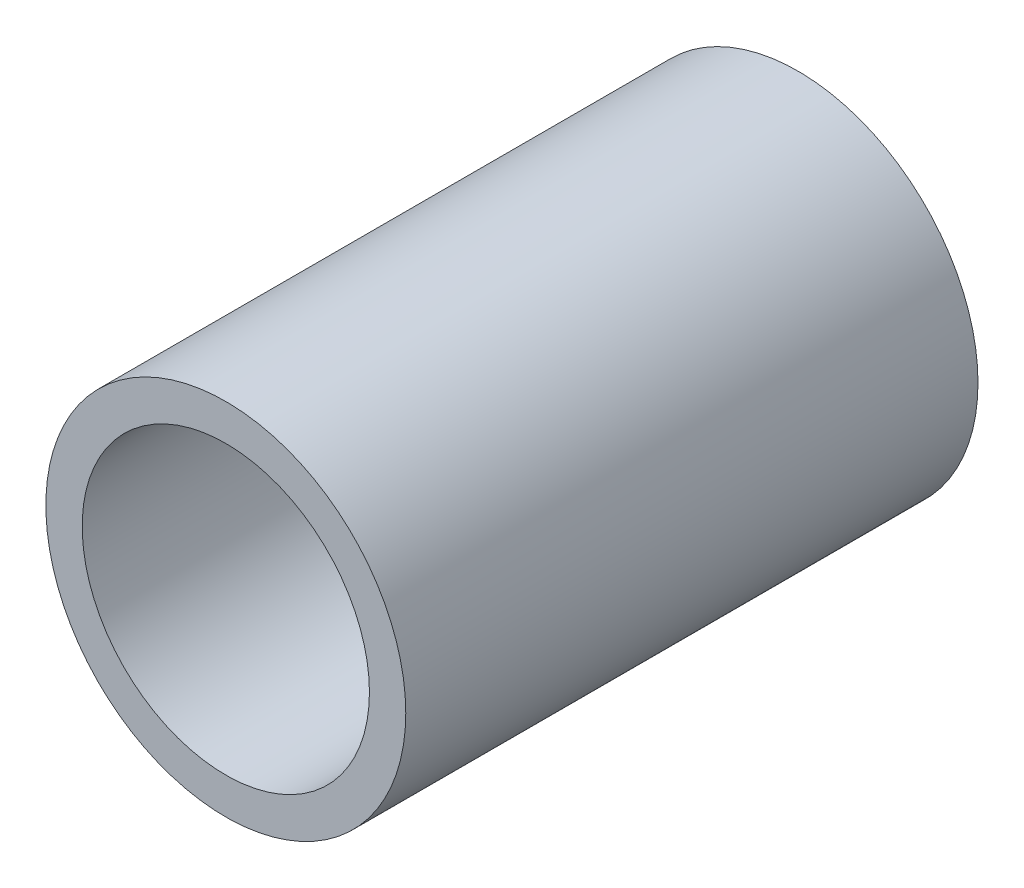
from build123d import *

# Parameters (mm, degrees)
SKETCH1_R      = 3.99415
SKETCH1_R_2    = 3.1877
EXTRUDE1_DEPTH = 6.35


with BuildPart() as part:
    # Sketch1 → Extrude1 (new body, symmetric)
    with BuildSketch(Plane.XY):
        Circle(SKETCH1_R)
        Circle(SKETCH1_R_2, mode=Mode.SUBTRACT)
    extrude(amount=EXTRUDE1_DEPTH, both=True)


solid = part.part
